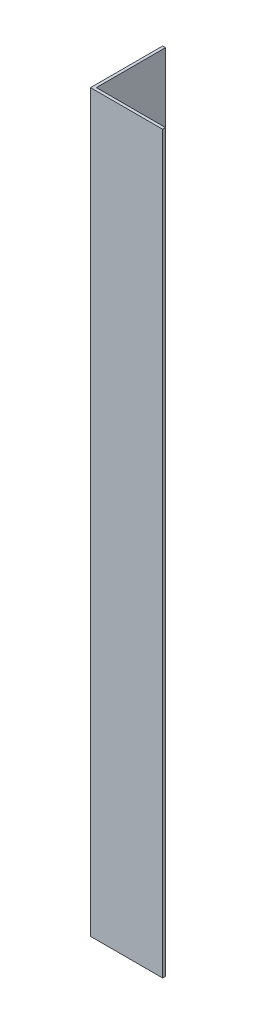
from build123d import *

# Parameters (mm, degrees)
BOSS_EXTRUDE1_DEPTH = 647.7


with BuildPart() as part:
    # Sketch1 → Boss-Extrude1 (new body)
    with BuildSketch(Plane(origin=(0, 0, 0), x_dir=(1, 0, 0), z_dir=(0, 1, 0))):
        Polygon((0, 0), (63.5, 0), (63.5, 2.54), (2.54, 2.54), (2.54, 63.5), (0, 63.5), align=None)
    extrude(amount=BOSS_EXTRUDE1_DEPTH)


solid = part.part
